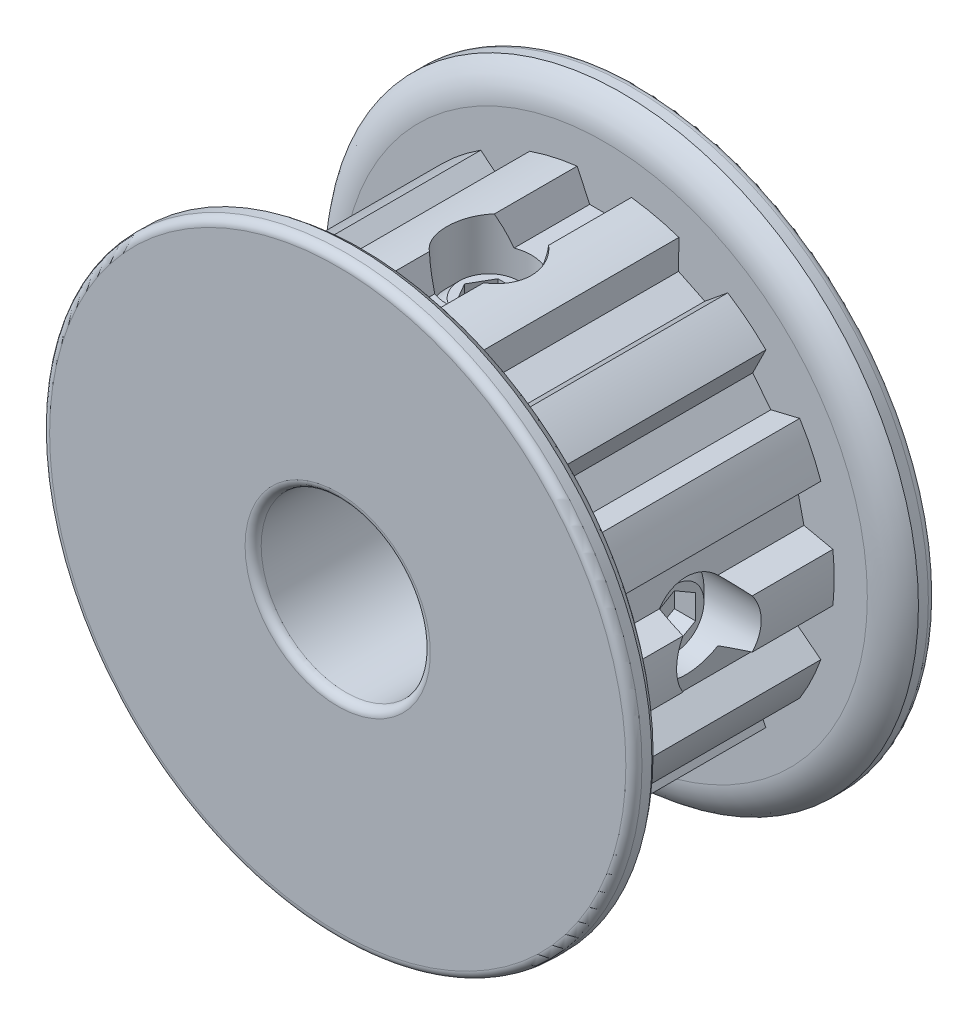
from build123d import *

# Parameters (mm, degrees)
CUT_EXTRUDE1_START = 5.45
CUT_EXTRUDE1_DEPTH = 10.9
CIRPATTERN1_COUNT  = 14
FILLET1_R          = 0.381
SKETCH5_R          = 2
CUT_EXTRUDE2_DEPTH = 22.050475121
CUT_EXTRUDE3_DEPTH = 1
CIRPATTERN2_COUNT  = 2
CIRPATTERN2_ANGLE  = 270


with BuildPart() as part:
    # Sketch2 → Revolve1 (revolve)
    with BuildSketch(Plane(origin=(0, 0, 0), x_dir=(0, 0, -1), z_dir=(1, 0, 0)), mode=Mode.PRIVATE) as revolve1_sk:
        with BuildLine():
            Line((-7.15, 4), (7.15, 4))
            Line((7.15, 4), (7.15, 14))
            Line((7.15, 14), (6.3, 14))
            ThreePointArc((6.3, 14), (5.67619825, 13.324895439), (5.45, 12.433980661))
            Line((5.45, 12.433980661), (5.45, 10.867961322))
            Line((5.45, 10.867961322), (-5.45, 10.867961322))
            Line((-5.45, 10.867961322), (-5.45, 12.433980661))
            ThreePointArc((-5.45, 12.433980661), (-5.67619825, 13.324895439), (-6.3, 14))
            Line((-6.3, 14), (-7.15, 14))
            Line((-7.15, 14), (-7.15, 4))
        make_face()
    revolve(revolve1_sk.sketch.rotate(Axis((0, 0, 7.15), (0, 0, -1)), 90), axis=Axis((0, 0, 7.15), (0, 0, -1)))

    # Sketch3 → Cut-Extrude1 (cut)
    with BuildSketch(Plane.XY.offset(CUT_EXTRUDE1_START)):
        with BuildLine():
            Line((-0.690489274, 9.522), (0.690489274, 9.522))
            Line((0.690489274, 9.522), (1.2827, 10.792))
            ThreePointArc((1.2827, 10.792), (0, 10.867961322), (-1.2827, 10.792))
            Line((-1.2827, 10.792), (-0.690489274, 9.522))
        make_face()
    cut_extrude1 = extrude(amount=-CUT_EXTRUDE1_DEPTH, mode=Mode.SUBTRACT)

    # CirPattern1: Cut-Extrude1 ×14 about axis
    cirpattern1_axis = Axis((0, 0, 0), (0, 0, 1))
    for i in range(1, CIRPATTERN1_COUNT):
        add(cut_extrude1.rotate(cirpattern1_axis, i * 360 / CIRPATTERN1_COUNT), mode=Mode.SUBTRACT)

    # Fillet1
    fillet1_edges = [part.edges().sort_by_distance(p)[0] for p in [
        (-14, 0, -7.15),
        (-4, 0, -7.15),
        (-4, 0, 7.15),
        (-14, 0, 7.15),
    ]]
    fillet(fillet1_edges, radius=FILLET1_R)

    # Sketch5 → Cut-Extrude2 (cut, through all)
    with BuildSketch(Plane(origin=(0, 0, 0), x_dir=(1, 0, 0), z_dir=(0, 1, 0))):
        with Locations(Location((0, 0, 0), (0, 0, 90))):
            Circle(SKETCH5_R)
    cut_extrude2 = extrude(amount=CUT_EXTRUDE2_DEPTH, mode=Mode.SUBTRACT)

    # Sketch6 → Revolve2 (revolve)
    with BuildSketch(Plane(origin=(0, 0, 0), x_dir=(0, 0, -1), z_dir=(1, 0, 0)), mode=Mode.PRIVATE) as revolve2_sk:
        Polygon((0, 8.76), (0, 4.762), (-1.4, 4.762), (-2, 5.362), (-2, 8.16), (-1.4, 8.76), align=None)
    revolve2 = revolve(revolve2_sk.sketch.rotate(Axis((0, 8.76, 0), (0, -1, 0)), 180), axis=Axis((0, 8.76, 0), (0, -1, 0)))

    # Sketch7 → Cut-Extrude3 (cut)
    with BuildSketch(Plane(origin=(0, 8.76, 0), x_dir=(1, 0, 0), z_dir=(0, 1, 0))):
        Polygon((1.154700538, 0), (0.577350269, 1), (-0.577350269, 1), (-1.154700538, 0), (-0.577350269, -1), (0.577350269, -1), align=None)
    cut_extrude3 = extrude(amount=-CUT_EXTRUDE3_DEPTH, mode=Mode.SUBTRACT)

    # CirPattern2: Cut-Extrude2, Revolve2, Cut-Extrude3 ×2 about axis
    cirpattern2_axis = Axis((0, 0, 0), (0, 0, 1))
    add([cut_extrude2.rotate(cirpattern2_axis, i * CIRPATTERN2_ANGLE / (CIRPATTERN2_COUNT - 1)) for i in range(1, CIRPATTERN2_COUNT)], mode=Mode.SUBTRACT)
    add([revolve2.rotate(cirpattern2_axis, i * CIRPATTERN2_ANGLE / (CIRPATTERN2_COUNT - 1)) for i in range(1, CIRPATTERN2_COUNT)])
    add([cut_extrude3.rotate(cirpattern2_axis, i * CIRPATTERN2_ANGLE / (CIRPATTERN2_COUNT - 1)) for i in range(1, CIRPATTERN2_COUNT)], mode=Mode.SUBTRACT)


solid = part.part
